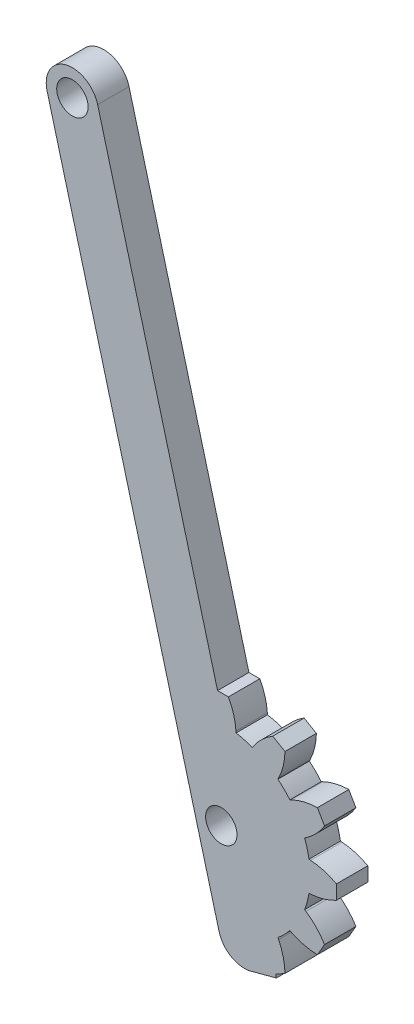
from build123d import *

# Parameters (mm, degrees)
SKETCH1_R           = 1.5
BOSS_EXTRUDE1_DEPTH = 3


with BuildPart() as part:
    # Sketch1 → Boss-Extrude1 (new body)
    with BuildSketch(Plane.XY.offset(1.9)):
        with BuildLine():
            Line((-16.649862046, 52.478872833), (-0.214852682, -8.857417136))
            ThreePointArc((-0.214852682, -8.857417136), (0.949961883, -10.375433033), (2.847009496, -10.625184089))
            Line((2.847009496, -10.625184089), (5.261824062, -9.978136476))
            Line((5.261824062, -9.978136476), (5.188879797, -9.705904774))
            Line((5.188879797, -9.705904774), (6.08761429, -9.187020173))
            ThreePointArc((6.08761429, -9.187020173), (5.919814799, -7.906537121), (5.481893659, -6.691622066))
            Line((5.481893659, -6.691622066), (5.414116812, -6.552658937))
            ThreePointArc((5.414116812, -6.552658937), (6.01040764, -6.01040764), (6.552658937, -5.414116812))
            Line((6.552658937, -5.414116812), (6.691622066, -5.481893659))
            ThreePointArc((6.691622066, -5.481893659), (7.906537121, -5.919814799), (9.187020173, -6.08761429))
            Line((9.187020173, -6.08761429), (9.86553871, -4.91238571))
            ThreePointArc((9.86553871, -4.91238571), (9.079978562, -3.887354604), (8.093270203, -3.054167872))
            Line((8.093270203, -3.054167872), (7.965092167, -2.967710696))
            ThreePointArc((7.965092167, -2.967710696), (8.210369523, -2.199961883), (8.381827508, -1.41243323))
            Line((8.381827508, -1.41243323), (8.536061531, -1.401648137))
            ThreePointArc((8.536061531, -1.401648137), (9.807169402, -1.173441441), (11, -0.678518537))
            Line((11, -0.678518537), (11, 0.678518537))
            ThreePointArc((11, 0.678518537), (9.807169402, 1.173441441), (8.536061531, 1.401648137))
            Line((8.536061531, 1.401648137), (8.381827508, 1.41243323))
            ThreePointArc((8.381827508, 1.41243323), (8.210369523, 2.199961883), (7.965092167, 2.967710696))
            Line((7.965092167, 2.967710696), (8.093270203, 3.054167872))
            ThreePointArc((8.093270203, 3.054167872), (9.079978562, 3.887354604), (9.86553871, 4.91238571))
            Line((9.86553871, 4.91238571), (9.187020173, 6.08761429))
            ThreePointArc((9.187020173, 6.08761429), (7.906537121, 5.919814799), (6.691622066, 5.481893659))
            Line((6.691622066, 5.481893659), (6.552658937, 5.414116812))
            ThreePointArc((6.552658937, 5.414116812), (6.01040764, 6.01040764), (5.414116812, 6.552658937))
            Line((5.414116812, 6.552658937), (5.481893659, 6.691622066))
            ThreePointArc((5.481893659, 6.691622066), (5.919814799, 7.906537121), (6.08761429, 9.187020173))
            Line((6.08761429, 9.187020173), (4.91238571, 9.86553871))
            ThreePointArc((4.91238571, 9.86553871), (3.887354604, 9.079978562), (3.054167872, 8.093270203))
            Line((3.054167872, 8.093270203), (2.967710696, 7.965092167))
            ThreePointArc((2.967710696, 7.965092167), (2.199961883, 8.210369523), (1.41243323, 8.381827508))
            Line((1.41243323, 8.381827508), (1.401648136, 8.536061531))
            ThreePointArc((1.401648136, 8.536061531), (1.173441441, 9.807169402), (0.678518537, 11))
            Line((0.678518537, 11), (-0.359250666, 11))
            Line((-0.359250666, 11), (-11.820232915, 53.772968059))
            ThreePointArc((-11.820232915, 53.772968059), (-14.882095093, 55.540735012), (-16.649862046, 52.478872833))
        make_face()
        with Locations((-14.235047481, 53.125920446)):
            Circle(SKETCH1_R, mode=Mode.SUBTRACT)
        Circle(SKETCH1_R, mode=Mode.SUBTRACT)
    extrude(amount=-BOSS_EXTRUDE1_DEPTH)


solid = part.part
